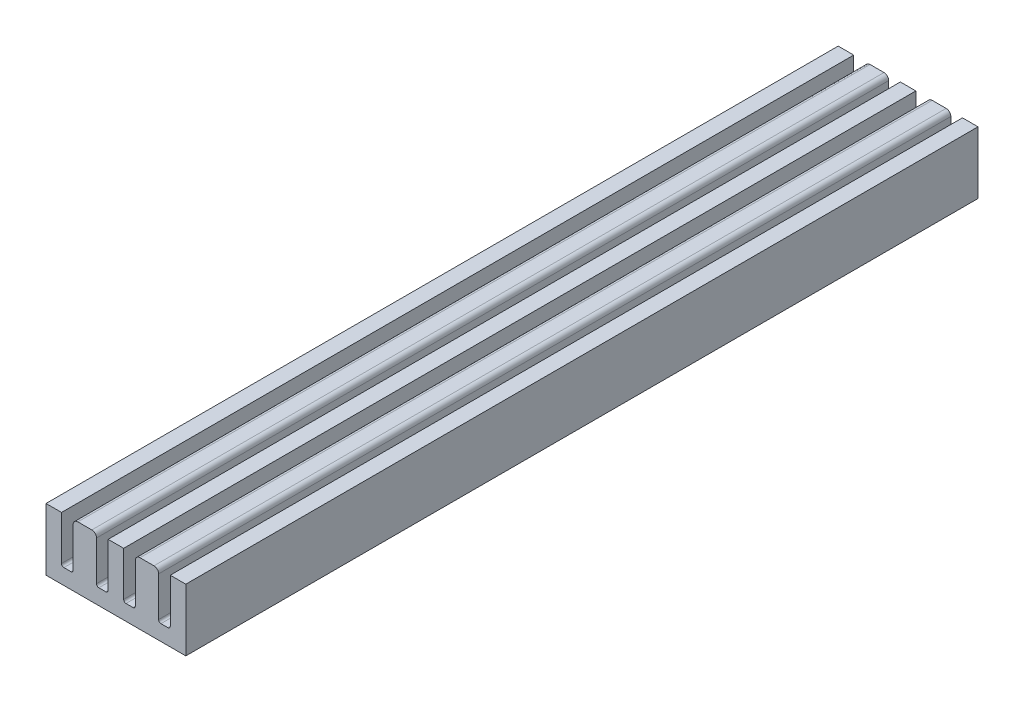
from build123d import *

# Parameters (mm, degrees)
ESBO_O1_W                = 3
ESBO_O1_H                = 6
RESSALTO_EXTRUS_O1_DEPTH = 102
RESSALTO_EXTRUS_O3_DEPTH = 102
RESSALTO_EXTRUS_O4_DEPTH = 102
FILETE3_R                = 0.6


with BuildPart() as part:
    # Esboço1 → Ressalto-extrusão1 (new body)
    with BuildSketch(Plane.XY):
        with Locations((-2, -34.87037037)):
            Rectangle(ESBO_O1_W, ESBO_O1_H)
    extrude(amount=RESSALTO_EXTRUS_O1_DEPTH)

    # Esboço1<6> → Ressalto-extrusão3 (add)
    with BuildSketch(Plane.XY):
        with BuildLine():
            Line((-3.801867323, -37.87037037), (-3.5, -37.87037037))
            Line((-3.5, -37.87037037), (-3.5, -37.568503047))
            ThreePointArc((-3.5, -37.568503047), (-3.588414892, -37.781955478), (-3.801867323, -37.87037037))
        make_face()
        with BuildLine():
            ThreePointArc((-4.698132677, -37.87037037), (-4.911585108, -37.781955478), (-5, -37.568503047))
            Line((-5, -37.568503047), (-5, -31.87037037))
            Line((-5, -31.87037037), (-7, -31.87037037))
            Line((-7, -31.87037037), (-7, -37.87037037))
            Line((-7, -37.87037037), (-4.698132677, -37.87037037))
        make_face()
        with BuildLine():
            Line((-0.5, -37.568503047), (-0.5, -37.87037037))
            Line((-0.5, -37.87037037), (-0.198132677, -37.87037037))
            ThreePointArc((-0.198132677, -37.87037037), (-0.411585108, -37.781955478), (-0.5, -37.568503047))
        make_face()
        with BuildLine():
            ThreePointArc((1, -37.568503047), (0.911585108, -37.781955478), (0.698132677, -37.87037037))
            Line((0.698132677, -37.87037037), (3.301867323, -37.87037037))
            ThreePointArc((3.301867323, -37.87037037), (3.088414892, -37.781955478), (3, -37.568503047))
            Line((3, -37.568503047), (3, -31.87037037))
            Line((3, -31.87037037), (1, -31.87037037))
            Line((1, -31.87037037), (1, -37.568503047))
        make_face()
        with BuildLine():
            Line((11, -37.87037037), (11, -31.87037037))
            Line((11, -31.87037037), (9, -31.87037037))
            Line((9, -31.87037037), (9, -37.568503047))
            ThreePointArc((9, -37.568503047), (8.911585108, -37.781955478), (8.698132677, -37.87037037))
            Line((8.698132677, -37.87037037), (11, -37.87037037))
        make_face()
        with BuildLine():
            ThreePointArc((4.5, -37.568503047), (4.411585108, -37.781955478), (4.198132677, -37.87037037))
            Line((4.198132677, -37.87037037), (7.801867323, -37.87037037))
            ThreePointArc((7.801867323, -37.87037037), (7.588414892, -37.781955478), (7.5, -37.568503047))
            Line((7.5, -37.568503047), (7.5, -31.87037037))
            Line((7.5, -31.87037037), (4.5, -31.87037037))
            Line((4.5, -31.87037037), (4.5, -37.568503047))
        make_face()
    extrude(amount=RESSALTO_EXTRUS_O3_DEPTH)


with BuildPart() as ressalto_extrus_o3_piece_1:
    # of the separate pieces the step leaves, piece 1, a body of its own (ressalto_extrus_o3_pieces)
    add(part.part.solids().sort_by_distance((-0.5, -37.568503047, 0))[0])



with BuildPart() as ressalto_extrus_o3_piece_2:
    # of the separate pieces the step leaves, piece 2, a body of its own (ressalto_extrus_o3_pieces)
    add(part.part.solids().sort_by_distance((4.5, -37.568503047, 0))[0])


with BuildPart() as ressalto_extrus_o3_piece_3:
    # of the separate pieces the step leaves, piece 3, a body of its own (ressalto_extrus_o3_pieces)
    add(part.part.solids().sort_by_distance((1, -37.568503047, 0))[0])


with BuildPart() as ressalto_extrus_o3_piece_4:
    # of the separate pieces the step leaves, piece 4, a body of its own (ressalto_extrus_o3_pieces)
    add(part.part.solids().sort_by_distance((11, -37.87037037, 0))[0])


with BuildPart() as ressalto_extrus_o3_piece_5:
    # of the separate pieces the step leaves, piece 5, a body of its own (ressalto_extrus_o3_pieces)
    add(part.part.solids().sort_by_distance((-4.698132677, -37.87037037, 0))[0])


with BuildPart() as ressalto_extrus_o3_piece_1_1:
    add(ressalto_extrus_o3_piece_1.part)

    add(ressalto_extrus_o3_piece_2.part)  # Ressalto-extrusão4 merges Ressalto-extrusão3 piece 2

    add(ressalto_extrus_o3_piece_3.part)  # Ressalto-extrusão4 merges Ressalto-extrusão3 piece 3

    add(ressalto_extrus_o3_piece_4.part)  # Ressalto-extrusão4 merges Ressalto-extrusão3 piece 4

    add(ressalto_extrus_o3_piece_5.part)  # Ressalto-extrusão4 merges Ressalto-extrusão3 piece 5
    # Esboço1<7> → Ressalto-extrusão4 (add)
    with BuildSketch(Plane.XY):
        Polygon((-2, -37.87037037), (-3.5, -37.87037037), (-3.801867323, -37.87037037), (-4.698132677, -37.87037037), (-5, -37.87037037), (-7, -37.87037037), (-7, -39.87037037), (11, -39.87037037), (11, -37.87037037), (9, -37.87037037), (8.698132677, -37.87037037), (7.801867323, -37.87037037), (7.5, -37.87037037), (6, -37.87037037), (4.5, -37.87037037), (4.198132677, -37.87037037), (3.301867323, -37.87037037), (3, -37.87037037), (1, -37.87037037), (0.698132677, -37.87037037), (-0.198132677, -37.87037037), (-0.5, -37.87037037), align=None)
    extrude(amount=RESSALTO_EXTRUS_O4_DEPTH)

    # Filete3
    filete3_edges = [ressalto_extrus_o3_piece_1_1.edges().sort_by_distance(p)[0] for p in [
        (7.5, -31.87037037, 51),
        (4.5, -31.87037037, 51),
        (-0.5, -31.87037037, 51),
        (-3.5, -31.87037037, 51),
    ]]
    fillet(filete3_edges, radius=FILETE3_R)


solid = ressalto_extrus_o3_piece_1_1.part
